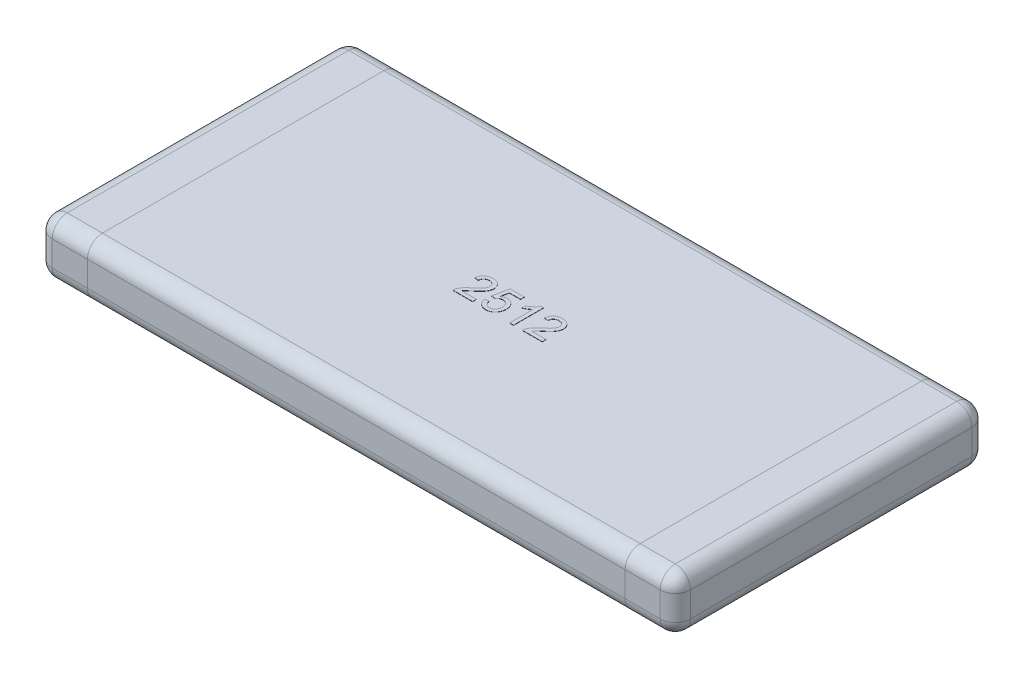
from build123d import *

# Parameters (mm, degrees)
SKETCH1_W      = 6.35
SKETCH1_H      = 3.1
EXTRUDE1_DEPTH = 0.55
FILLET1_R      = 0.15
EXTRUDE2_DEPTH = 0.002


with BuildPart() as part:
    # Sketch1 → Extrude1 (new body)
    with BuildSketch(Plane(origin=(0, 0, 0), x_dir=(1, 0, 0), z_dir=(0, 1, 0))):
        Rectangle(SKETCH1_W, SKETCH1_H)
    extrude(amount=EXTRUDE1_DEPTH)

    # Fillet1
    fillet1_edges = [part.edges().sort_by_distance(p)[0] for p in [
        (3.175, 0.55, 0),
        (0, 0.55, -1.55),
        (-3.175, 0.55, 0),
        (0, 0, -1.55),
        (3.175, 0, 0),
        (0, 0, 1.55),
        (-3.175, 0, 0),
        (0, 0.55, 1.55),
        (-3.175, 0.275, -1.55),
        (3.175, 0.275, -1.55),
        (3.175, 0.275, 1.55),
        (-3.175, 0.275, 1.55),
    ]]
    fillet(fillet1_edges, radius=FILLET1_R)

    # Sketch3 → Extrude2 (add)
    with BuildSketch(Plane(origin=(0, 0.55, 0), x_dir=(1, 0, 0), z_dir=(0, 1, 0))):
        with BuildLine():
            Line((-0.242307692, -0.111538462), (-0.242307692, -0.15))
            Line((-0.242307692, -0.15), (-0.438461538, -0.15))
            add(Edge.make_bspline(
                [(-0.438461538, -0.15), (-0.438465554, -0.147714123), (-0.438473572, -0.14315003), (-0.437701254, -0.136400026), (-0.43649165, -0.129739566), (-0.43512395, -0.125468478), (-0.434435096, -0.123317308)],
                knots=[0, 0, 0, 0, 6.852e-06, 1.3681e-05, 2.0352e-05, 2.7121e-05, 2.7121e-05, 2.7121e-05, 2.7121e-05], degree=3))
            add(Edge.make_bspline(
                [(-0.434435096, -0.123317308), (-0.433162323, -0.119802551), (-0.430570749, -0.112645929), (-0.425320191, -0.102319922), (-0.419144294, -0.092056365), (-0.413131189, -0.08370038), (-0.407624483, -0.077024532), (-0.403006393, -0.071801454), (-0.397888702, -0.066455018), (-0.392275509, -0.060986201), (-0.386220838, -0.055359583), (-0.379716427, -0.049556401), (-0.37268547, -0.043684801), (-0.367777126, -0.039792861), (-0.365264423, -0.037800481)],
                knots=[0, 0, 0, 0, 1.1205e-05, 2.2816e-05, 3.4678e-05, 4.712e-05, 5.3653e-05, 6.0635e-05, 6.8031e-05, 7.5851e-05, 8.4142e-05, 9.2826e-05, 0.000101998, 0.000111618, 0.000111618, 0.000111618, 0.000111618], degree=3))
            add(Edge.make_bspline(
                [(-0.365264423, -0.037800481), (-0.361404291, -0.034551471), (-0.353971363, -0.028295295), (-0.343474903, -0.019011711), (-0.333888095, -0.010391377), (-0.325363599, -0.002283205), (-0.317831693, 0.005234162), (-0.311274691, 0.012143692), (-0.305636176, 0.018423822), (-0.300984983, 0.024301865), (-0.297060629, 0.029852373), (-0.293735085, 0.035266551), (-0.290963685, 0.040638972), (-0.28865548, 0.045952637), (-0.286829886, 0.05123027), (-0.285585484, 0.056487246), (-0.284741574, 0.061671403), (-0.28465714, 0.065120999), (-0.284615385, 0.066826923)],
                knots=[0, 0, 0, 0, 1.5136e-05, 2.9145e-05, 4.2036e-05, 5.3811e-05, 6.4435e-05, 7.3957e-05, 8.2386e-05, 8.9745e-05, 9.643e-05, 0.000102769, 0.00010879, 0.00011455, 0.000120137, 0.000125516, 0.000130743, 0.000135857, 0.000135857, 0.000135857, 0.000135857], degree=3))
            add(Edge.make_bspline(
                [(-0.284615385, 0.066826923), (-0.284657145, 0.068512943), (-0.284739075, 0.071820821), (-0.285516432, 0.076661881), (-0.286598573, 0.081323937), (-0.288348068, 0.085723063), (-0.290430492, 0.089989532), (-0.293101705, 0.093988532), (-0.296191748, 0.097819726), (-0.299729586, 0.101382104), (-0.303593734, 0.104724183), (-0.307911369, 0.107502263), (-0.312398909, 0.110003363), (-0.317211172, 0.11201439), (-0.322340336, 0.113491124), (-0.327749065, 0.114562852), (-0.333436501, 0.115242385), (-0.337317775, 0.115336486), (-0.339302885, 0.115384615)],
                knots=[0, 0, 0, 0, 5.054e-06, 9.915e-06, 1.4681e-05, 1.938e-05, 2.4083e-05, 2.89e-05, 3.3772e-05, 3.8829e-05, 4.3946e-05, 4.9063e-05, 5.4199e-05, 5.9345e-05, 6.4669e-05, 7.0185e-05, 7.5872e-05, 8.1827e-05, 8.1827e-05, 8.1827e-05, 8.1827e-05], degree=3))
            add(Edge.make_bspline(
                [(-0.339302885, 0.115384615), (-0.341388187, 0.115336725), (-0.345469276, 0.115242999), (-0.351434735, 0.114560756), (-0.357097905, 0.113518381), (-0.362445268, 0.111924678), (-0.367470315, 0.109917004), (-0.372152582, 0.107389877), (-0.376567049, 0.104537208), (-0.38057469, 0.101159863), (-0.384198747, 0.097415076), (-0.387416066, 0.093338135), (-0.390052175, 0.088850365), (-0.392229183, 0.084050442), (-0.393979679, 0.078923275), (-0.39525048, 0.07342967), (-0.395943329, 0.067585487), (-0.396082655, 0.063583392), (-0.396153846, 0.061538462)],
                knots=[0, 0, 0, 0, 6.255e-06, 1.2241e-05, 1.7992e-05, 2.3507e-05, 2.8953e-05, 3.4195e-05, 3.9446e-05, 4.4693e-05, 4.9878e-05, 5.506e-05, 6.0233e-05, 6.5451e-05, 7.0848e-05, 7.6461e-05, 8.2334e-05, 8.8471e-05, 8.8471e-05, 8.8471e-05, 8.8471e-05], degree=3))
            Line((-0.396153846, 0.061538462), (-0.434615385, 0.065384615))
            add(Edge.make_bspline(
                [(-0.434615385, 0.065384615), (-0.434221868, 0.068736632), (-0.433456317, 0.075257693), (-0.431549431, 0.084702351), (-0.428872337, 0.09348859), (-0.425668968, 0.101738909), (-0.421653243, 0.109312863), (-0.417113811, 0.11636711), (-0.411759761, 0.122677919), (-0.405844956, 0.128444216), (-0.399304593, 0.133525841), (-0.392200109, 0.137965346), (-0.384534753, 0.141678718), (-0.376351219, 0.144753235), (-0.367630719, 0.147085948), (-0.358385591, 0.148758724), (-0.348600965, 0.149789842), (-0.341889572, 0.149928948), (-0.338461538, 0.15)],
                knots=[0, 0, 0, 0, 1.0123e-05, 1.9693e-05, 2.8857e-05, 3.7651e-05, 4.6199e-05, 5.4533e-05, 6.2766e-05, 7.0968e-05, 7.9275e-05, 8.7563e-05, 9.6056e-05, 0.000104785, 0.00011375, 0.000123098, 0.000132946, 0.000143229, 0.000143229, 0.000143229, 0.000143229], degree=3))
            add(Edge.make_bspline(
                [(-0.338461538, 0.15), (-0.334992474, 0.149940596), (-0.328234715, 0.149824877), (-0.318387574, 0.14864084), (-0.309096525, 0.146796713), (-0.300327506, 0.144226564), (-0.292132326, 0.140856333), (-0.284504682, 0.136738671), (-0.277409403, 0.131913745), (-0.270965038, 0.126323636), (-0.265153985, 0.120221095), (-0.260061454, 0.113708369), (-0.255803853, 0.106813279), (-0.25217877, 0.09962981), (-0.249489912, 0.092006182), (-0.247599058, 0.084046037), (-0.246314167, 0.075742575), (-0.246207997, 0.070077103), (-0.246153846, 0.0671875)],
                knots=[0, 0, 0, 0, 1.0403e-05, 2.0265e-05, 2.9705e-05, 3.8794e-05, 4.7633e-05, 5.6238e-05, 6.4755e-05, 7.3321e-05, 8.178e-05, 9.0002e-05, 9.8073e-05, 0.000106055, 0.000114096, 0.000122258, 0.000130579, 0.00013924, 0.00013924, 0.00013924, 0.00013924], degree=3))
            add(Edge.make_bspline(
                [(-0.246153846, 0.0671875), (-0.246236534, 0.06421876), (-0.246402091, 0.058274728), (-0.247694287, 0.049390154), (-0.24990525, 0.040601997), (-0.252836396, 0.0318033), (-0.256840951, 0.022959142), (-0.261900028, 0.013947517), (-0.268176364, 0.004735138), (-0.27421244, -0.003096409), (-0.279831048, -0.009661219), (-0.284811412, -0.015064442), (-0.290573405, -0.020805005), (-0.296900874, -0.027081717), (-0.304051882, -0.033671804), (-0.311820964, -0.040772611), (-0.32037819, -0.048197271), (-0.326318573, -0.053269443), (-0.329387019, -0.055889423)],
                knots=[0, 0, 0, 0, 8.904e-06, 1.7828e-05, 2.6865e-05, 3.6063e-05, 4.5612e-05, 5.5944e-05, 6.7028e-05, 7.9024e-05, 8.5588e-05, 9.2946e-05, 0.000101063, 0.000109987, 0.000119681, 0.000130232, 0.000141562, 0.000153666, 0.000153666, 0.000153666, 0.000153666], degree=3))
            add(Edge.make_bspline(
                [(-0.329387019, -0.055889423), (-0.33201468, -0.058028619), (-0.337025225, -0.062107737), (-0.344153696, -0.068021343), (-0.350538638, -0.07344396), (-0.356329361, -0.078198712), (-0.361314972, -0.08251558), (-0.365671081, -0.086205504), (-0.369239429, -0.089454013), (-0.374673391, -0.094388563), (-0.381555968, -0.101422266), (-0.386627345, -0.108256719), (-0.3890625, -0.111538462)],
                knots=[0, 0, 0, 0, 1.0165e-05, 1.9383e-05, 2.7786e-05, 3.5295e-05, 4.1859e-05, 4.7569e-05, 5.242e-05, 5.6334e-05, 6.9594e-05, 8.1844e-05, 8.1844e-05, 8.1844e-05, 8.1844e-05], degree=3))
            Line((-0.3890625, -0.111538462), (-0.242307692, -0.111538462))
        make_face()
        with BuildLine():
            Line((-0.2, -0.069230769), (-0.161538462, -0.065384615))
            add(Edge.make_bspline(
                [(-0.161538462, -0.065384615), (-0.161157632, -0.067551712), (-0.160416859, -0.071767052), (-0.159005235, -0.077868882), (-0.157171936, -0.083537652), (-0.155112024, -0.088822457), (-0.15266347, -0.093667418), (-0.150010442, -0.098149034), (-0.146881737, -0.102108221), (-0.143592325, -0.105752048), (-0.139981943, -0.108962904), (-0.136015755, -0.111669767), (-0.131804419, -0.114031341), (-0.127296644, -0.115964892), (-0.12248552, -0.11738015), (-0.11743228, -0.118499376), (-0.112071855, -0.119063349), (-0.108414474, -0.119174249), (-0.106550481, -0.119230769)],
                knots=[0, 0, 0, 0, 6.601e-06, 1.2839e-05, 1.8769e-05, 2.4461e-05, 2.9836e-05, 3.5041e-05, 4.0053e-05, 4.4945e-05, 4.9756e-05, 5.4507e-05, 5.9322e-05, 6.4223e-05, 6.9184e-05, 7.4347e-05, 7.9729e-05, 8.5323e-05, 8.5323e-05, 8.5323e-05, 8.5323e-05], degree=3))
            add(Edge.make_bspline(
                [(-0.106550481, -0.119230769), (-0.104263779, -0.119175516), (-0.099792033, -0.119067466), (-0.09328649, -0.118153619), (-0.087141479, -0.116646792), (-0.0813864, -0.1145381), (-0.075953789, -0.111915691), (-0.071023867, -0.10852015), (-0.066327829, -0.104703226), (-0.062167866, -0.10015272), (-0.058381131, -0.095198734), (-0.055112894, -0.089791248), (-0.0523615, -0.08400616), (-0.050045127, -0.077844578), (-0.048334654, -0.071271305), (-0.047076464, -0.064321309), (-0.046268755, -0.056990161), (-0.046192692, -0.051965295), (-0.046153846, -0.049399038)],
                knots=[0, 0, 0, 0, 6.858e-06, 1.341e-05, 1.9663e-05, 2.5804e-05, 3.177e-05, 3.7704e-05, 4.3721e-05, 4.9886e-05, 5.6149e-05, 6.2405e-05, 6.8802e-05, 7.5343e-05, 8.2122e-05, 8.9147e-05, 9.652e-05, 0.000104216, 0.000104216, 0.000104216, 0.000104216], degree=3))
            add(Edge.make_bspline(
                [(-0.046153846, -0.049399038), (-0.046197998, -0.04695343), (-0.046283972, -0.042191262), (-0.047008016, -0.035256754), (-0.048229562, -0.028736217), (-0.049810129, -0.022557785), (-0.05198874, -0.016818003), (-0.054572696, -0.01143365), (-0.057738151, -0.006518997), (-0.061259928, -0.001921019), (-0.065282243, 0.002200882), (-0.069859435, 0.005681305), (-0.074811944, 0.008727379), (-0.080239519, 0.011197555), (-0.086145356, 0.013032802), (-0.092470767, 0.01444486), (-0.099281388, 0.015187545), (-0.103964807, 0.015317745), (-0.106370192, 0.015384615)],
                knots=[0, 0, 0, 0, 7.336e-06, 1.4284e-05, 2.0885e-05, 2.7226e-05, 3.3387e-05, 3.9274e-05, 4.5109e-05, 5.0891e-05, 5.6628e-05, 6.2325e-05, 6.8097e-05, 7.4041e-05, 8.016e-05, 8.662e-05, 9.3456e-05, 0.000100674, 0.000100674, 0.000100674, 0.000100674], degree=3))
            add(Edge.make_bspline(
                [(-0.106370192, 0.015384615), (-0.109361172, 0.015297123), (-0.115097193, 0.015129334), (-0.123339267, 0.013717778), (-0.130842324, 0.011437589), (-0.137521417, 0.008039245), (-0.143488856, 0.003979366), (-0.148868613, -0.000614572), (-0.153705047, -0.005739463), (-0.156358029, -0.009597911), (-0.157692308, -0.011538462)],
                knots=[0, 0, 0, 0, 8.967e-06, 1.7197e-05, 2.5009e-05, 3.24e-05, 3.9584e-05, 4.6617e-05, 5.3591e-05, 6.0647e-05, 6.0647e-05, 6.0647e-05, 6.0647e-05], degree=3))
            Line((-0.157692308, -0.011538462), (-0.196153846, -0.007692308))
            Line((-0.196153846, -0.007692308), (-0.165384615, 0.146153846))
            Line((-0.165384615, 0.146153846), (-0.023076923, 0.146153846))
            Line((-0.023076923, 0.146153846), (-0.023076923, 0.107692308))
            Line((-0.023076923, 0.107692308), (-0.133954327, 0.107692308))
            Line((-0.133954327, 0.107692308), (-0.14921875, 0.029987981))
            add(Edge.make_bspline(
                [(-0.14921875, 0.029987981), (-0.147096545, 0.031580513), (-0.142928871, 0.034707994), (-0.136428046, 0.038803019), (-0.129834266, 0.042254851), (-0.123185915, 0.045081612), (-0.116430183, 0.047283653), (-0.109607836, 0.04881353), (-0.102695646, 0.049847511), (-0.098060615, 0.049949025), (-0.095733173, 0.05)],
                knots=[0, 0, 0, 0, 7.957e-06, 1.5627e-05, 2.3019e-05, 3.0263e-05, 3.7276e-05, 4.4303e-05, 5.1221e-05, 5.8199e-05, 5.8199e-05, 5.8199e-05, 5.8199e-05], degree=3))
            add(Edge.make_bspline(
                [(-0.095733173, 0.05), (-0.092704165, 0.049920638), (-0.086739314, 0.049764354), (-0.077949899, 0.048480285), (-0.06954574, 0.046300494), (-0.061460916, 0.043364633), (-0.053802033, 0.039472647), (-0.046491513, 0.034760279), (-0.039558872, 0.029188686), (-0.033043301, 0.022862992), (-0.027133419, 0.015840807), (-0.021843881, 0.008351149), (-0.017523676, 0.000244097), (-0.013890087, -0.008268674), (-0.011149556, -0.017326903), (-0.009069398, -0.026802035), (-0.007957206, -0.036812532), (-0.007781989, -0.043627351), (-0.007692308, -0.047115385)],
                knots=[0, 0, 0, 0, 9.084e-06, 1.7889e-05, 2.6576e-05, 3.5094e-05, 4.3641e-05, 5.2292e-05, 6.1143e-05, 7.028e-05, 7.9491e-05, 8.8643e-05, 9.7732e-05, 0.000106996, 0.000116367, 0.00012608, 0.000136061, 0.000146526, 0.000146526, 0.000146526, 0.000146526], degree=3))
            add(Edge.make_bspline(
                [(-0.007692308, -0.047115385), (-0.007760408, -0.050443542), (-0.007894924, -0.057017604), (-0.008997316, -0.066705698), (-0.010813244, -0.07604094), (-0.013244271, -0.085050973), (-0.016528915, -0.093684628), (-0.02051288, -0.101969792), (-0.025108607, -0.109992917), (-0.028794142, -0.114938711), (-0.030649038, -0.117427885)],
                knots=[0, 0, 0, 0, 9.982e-06, 1.9718e-05, 2.9206e-05, 3.8493e-05, 4.7679e-05, 5.6872e-05, 6.6056e-05, 7.5361e-05, 7.5361e-05, 7.5361e-05, 7.5361e-05], degree=3))
            add(Edge.make_bspline(
                [(-0.030649038, -0.117427885), (-0.033005632, -0.120333533), (-0.037641305, -0.126049256), (-0.045667922, -0.133467922), (-0.054296649, -0.139772767), (-0.063578837, -0.144894997), (-0.073452171, -0.149011142), (-0.084037943, -0.151750282), (-0.095208241, -0.153589724), (-0.102876868, -0.153759501), (-0.106790865, -0.153846154)],
                knots=[0, 0, 0, 0, 1.1212e-05, 2.2054e-05, 3.2681e-05, 4.3199e-05, 5.379e-05, 6.4679e-05, 7.5933e-05, 8.7664e-05, 8.7664e-05, 8.7664e-05, 8.7664e-05], degree=3))
            add(Edge.make_bspline(
                [(-0.106790865, -0.153846154), (-0.110019293, -0.153780666), (-0.116334744, -0.153652558), (-0.125581689, -0.152538848), (-0.134376627, -0.150762874), (-0.142722313, -0.148215578), (-0.150643892, -0.144996831), (-0.158049284, -0.140907918), (-0.165067002, -0.136230457), (-0.17154268, -0.130820335), (-0.177442866, -0.124785969), (-0.182729553, -0.118255214), (-0.187331197, -0.111223812), (-0.191245577, -0.103733837), (-0.194508032, -0.095792473), (-0.197003939, -0.087345515), (-0.198980905, -0.078475843), (-0.19965674, -0.072344773), (-0.2, -0.069230769)],
                knots=[0, 0, 0, 0, 9.682e-06, 1.894e-05, 2.7898e-05, 3.6567e-05, 4.5082e-05, 5.3499e-05, 6.19e-05, 7.0348e-05, 7.8763e-05, 8.7181e-05, 9.5515e-05, 0.000103929, 0.0001125, 0.000121226, 0.000130326, 0.000139718, 0.000139718, 0.000139718, 0.000139718], degree=3))
        make_face()
        with BuildLine():
            Line((0.165384615, -0.15), (0.126923077, -0.15))
            Line((0.126923077, -0.15), (0.126923077, 0.083774038))
            add(Edge.make_bspline(
                [(0.126923077, 0.083774038), (0.124708458, 0.081638311), (0.120105616, 0.077199436), (0.112324997, 0.070917319), (0.103640832, 0.064550127), (0.09416589, 0.05842736), (0.08450779, 0.052663436), (0.075174479, 0.047479672), (0.066321782, 0.04309295), (0.060490463, 0.040694273), (0.057692308, 0.039543269)],
                knots=[0, 0, 0, 0, 9.226e-06, 1.9175e-05, 2.9969e-05, 4.1521e-05, 5.3002e-05, 6.3707e-05, 7.3544e-05, 8.2619e-05, 8.2619e-05, 8.2619e-05, 8.2619e-05], degree=3))
            Line((0.057692308, 0.039543269), (0.057692308, 0.075))
            add(Edge.make_bspline(
                [(0.057692308, 0.075), (0.062498428, 0.077475162), (0.071971006, 0.082353558), (0.085353711, 0.09077922), (0.097847906, 0.099912985), (0.109246762, 0.10975283), (0.11946511, 0.119810917), (0.128076261, 0.129959923), (0.135281523, 0.139827828), (0.13889654, 0.146709597), (0.140625, 0.15)],
                knots=[0, 0, 0, 0, 1.6212e-05, 3.1953e-05, 4.7386e-05, 6.26e-05, 7.7091e-05, 9.0349e-05, 0.000102505, 0.000113642, 0.000113642, 0.000113642, 0.000113642], degree=3))
            Line((0.140625, 0.15), (0.165384615, 0.15))
            Line((0.165384615, 0.15), (0.165384615, -0.15))
        make_face()
        with BuildLine():
            Line((0.45, -0.111538462), (0.45, -0.15))
            Line((0.45, -0.15), (0.253846154, -0.15))
            add(Edge.make_bspline(
                [(0.253846154, -0.15), (0.253842138, -0.147714123), (0.25383412, -0.14315003), (0.254606438, -0.136400026), (0.255816043, -0.129739566), (0.257183742, -0.125468478), (0.257872596, -0.123317308)],
                knots=[0, 0, 0, 0, 6.852e-06, 1.3681e-05, 2.0352e-05, 2.7121e-05, 2.7121e-05, 2.7121e-05, 2.7121e-05], degree=3))
            add(Edge.make_bspline(
                [(0.257872596, -0.123317308), (0.259145369, -0.119802551), (0.261736944, -0.112645929), (0.266987502, -0.102319922), (0.273163399, -0.092056365), (0.279176504, -0.08370038), (0.284683209, -0.077024532), (0.2893013, -0.071801454), (0.294418991, -0.066455018), (0.300032183, -0.060986201), (0.306086854, -0.055359583), (0.312591265, -0.049556401), (0.319622223, -0.043684801), (0.324530567, -0.039792861), (0.327043269, -0.037800481)],
                knots=[0, 0, 0, 0, 1.1205e-05, 2.2816e-05, 3.4678e-05, 4.712e-05, 5.3653e-05, 6.0635e-05, 6.8031e-05, 7.5851e-05, 8.4142e-05, 9.2826e-05, 0.000101998, 0.000111618, 0.000111618, 0.000111618, 0.000111618], degree=3))
            add(Edge.make_bspline(
                [(0.327043269, -0.037800481), (0.330903401, -0.034551471), (0.33833633, -0.028295295), (0.348832789, -0.019011711), (0.358419597, -0.010391377), (0.366944093, -0.002283205), (0.374476, 0.005234162), (0.381033001, 0.012143692), (0.386671516, 0.018423822), (0.391322709, 0.024301865), (0.395247064, 0.029852373), (0.398572608, 0.035266551), (0.401344007, 0.040638972), (0.403652212, 0.045952637), (0.405477806, 0.05123027), (0.406722208, 0.056487246), (0.407566119, 0.061671403), (0.407650553, 0.065120999), (0.407692308, 0.066826923)],
                knots=[0, 0, 0, 0, 1.5136e-05, 2.9145e-05, 4.2036e-05, 5.3811e-05, 6.4435e-05, 7.3957e-05, 8.2386e-05, 8.9745e-05, 9.643e-05, 0.000102769, 0.00010879, 0.00011455, 0.000120137, 0.000125516, 0.000130743, 0.000135857, 0.000135857, 0.000135857, 0.000135857], degree=3))
            add(Edge.make_bspline(
                [(0.407692308, 0.066826923), (0.407650548, 0.068512943), (0.407568617, 0.071820821), (0.406791261, 0.076661881), (0.405709119, 0.081323937), (0.403959625, 0.085723063), (0.4018772, 0.089989532), (0.399205988, 0.093988532), (0.396115944, 0.097819726), (0.392578106, 0.101382104), (0.388713958, 0.104724183), (0.384396323, 0.107502263), (0.379908783, 0.110003363), (0.375096521, 0.11201439), (0.369967356, 0.113491124), (0.364558627, 0.114562852), (0.358871192, 0.115242385), (0.354989917, 0.115336486), (0.353004808, 0.115384615)],
                knots=[0, 0, 0, 0, 5.054e-06, 9.915e-06, 1.4681e-05, 1.938e-05, 2.4083e-05, 2.89e-05, 3.3772e-05, 3.8829e-05, 4.3946e-05, 4.9063e-05, 5.4199e-05, 5.9345e-05, 6.4669e-05, 7.0185e-05, 7.5872e-05, 8.1827e-05, 8.1827e-05, 8.1827e-05, 8.1827e-05], degree=3))
            add(Edge.make_bspline(
                [(0.353004808, 0.115384615), (0.350919506, 0.115336725), (0.346838417, 0.115242999), (0.340872957, 0.114560756), (0.335209788, 0.113518381), (0.329862425, 0.111924678), (0.324837377, 0.109917004), (0.320155111, 0.107389877), (0.315740643, 0.104537208), (0.311733002, 0.101159863), (0.308108946, 0.097415076), (0.304891627, 0.093338135), (0.302255517, 0.088850365), (0.30007851, 0.084050442), (0.298328013, 0.078923275), (0.297057212, 0.07342967), (0.296364363, 0.067585487), (0.296225037, 0.063583392), (0.296153846, 0.061538462)],
                knots=[0, 0, 0, 0, 6.255e-06, 1.2241e-05, 1.7992e-05, 2.3507e-05, 2.8953e-05, 3.4195e-05, 3.9446e-05, 4.4693e-05, 4.9878e-05, 5.506e-05, 6.0233e-05, 6.5451e-05, 7.0848e-05, 7.6461e-05, 8.2334e-05, 8.8471e-05, 8.8471e-05, 8.8471e-05, 8.8471e-05], degree=3))
            Line((0.296153846, 0.061538462), (0.257692308, 0.065384615))
            add(Edge.make_bspline(
                [(0.257692308, 0.065384615), (0.258085824, 0.068736632), (0.258851376, 0.075257693), (0.260758261, 0.084702351), (0.263435355, 0.09348859), (0.266638724, 0.101738909), (0.27065445, 0.109312863), (0.275193881, 0.11636711), (0.280547932, 0.122677919), (0.286462737, 0.128444216), (0.293003099, 0.133525841), (0.300107584, 0.137965346), (0.30777294, 0.141678718), (0.315956474, 0.144753235), (0.324676973, 0.147085948), (0.333922102, 0.148758724), (0.343706727, 0.149789842), (0.350418121, 0.149928948), (0.353846154, 0.15)],
                knots=[0, 0, 0, 0, 1.0123e-05, 1.9693e-05, 2.8857e-05, 3.7651e-05, 4.6199e-05, 5.4533e-05, 6.2766e-05, 7.0968e-05, 7.9275e-05, 8.7563e-05, 9.6056e-05, 0.000104785, 0.00011375, 0.000123098, 0.000132946, 0.000143229, 0.000143229, 0.000143229, 0.000143229], degree=3))
            add(Edge.make_bspline(
                [(0.353846154, 0.15), (0.357315219, 0.149940596), (0.364072977, 0.149824877), (0.373920118, 0.14864084), (0.383211167, 0.146796713), (0.391980186, 0.144226564), (0.400175366, 0.140856333), (0.40780301, 0.136738671), (0.414898289, 0.131913745), (0.421342655, 0.126323636), (0.427153708, 0.120221095), (0.432246239, 0.113708369), (0.43650384, 0.106813279), (0.440128923, 0.09962981), (0.44281778, 0.092006182), (0.444708635, 0.084046037), (0.445993525, 0.075742575), (0.446099695, 0.070077103), (0.446153846, 0.0671875)],
                knots=[0, 0, 0, 0, 1.0403e-05, 2.0265e-05, 2.9705e-05, 3.8794e-05, 4.7633e-05, 5.6238e-05, 6.4755e-05, 7.3321e-05, 8.178e-05, 9.0002e-05, 9.8073e-05, 0.000106055, 0.000114096, 0.000122258, 0.000130579, 0.00013924, 0.00013924, 0.00013924, 0.00013924], degree=3))
            add(Edge.make_bspline(
                [(0.446153846, 0.0671875), (0.446071159, 0.06421876), (0.445905602, 0.058274728), (0.444613405, 0.049390154), (0.442402443, 0.040601997), (0.439471297, 0.0318033), (0.435466741, 0.022959142), (0.430407665, 0.013947517), (0.424131328, 0.004735138), (0.418095252, -0.003096409), (0.412476645, -0.009661219), (0.40749628, -0.015064442), (0.401734287, -0.020805005), (0.395406818, -0.027081717), (0.38825581, -0.033671804), (0.380486728, -0.040772611), (0.371929502, -0.048197271), (0.36598912, -0.053269443), (0.362920673, -0.055889423)],
                knots=[0, 0, 0, 0, 8.904e-06, 1.7828e-05, 2.6865e-05, 3.6063e-05, 4.5612e-05, 5.5944e-05, 6.7028e-05, 7.9024e-05, 8.5588e-05, 9.2946e-05, 0.000101063, 0.000109987, 0.000119681, 0.000130232, 0.000141562, 0.000153666, 0.000153666, 0.000153666, 0.000153666], degree=3))
            add(Edge.make_bspline(
                [(0.362920673, -0.055889423), (0.360293012, -0.058028619), (0.355282467, -0.062107737), (0.348153996, -0.068021343), (0.341769055, -0.07344396), (0.335978331, -0.078198712), (0.33099272, -0.08251558), (0.326636611, -0.086205504), (0.323068263, -0.089454013), (0.317634301, -0.094388563), (0.310751724, -0.101422266), (0.305680348, -0.108256719), (0.303245192, -0.111538462)],
                knots=[0, 0, 0, 0, 1.0165e-05, 1.9383e-05, 2.7786e-05, 3.5295e-05, 4.1859e-05, 4.7569e-05, 5.242e-05, 5.6334e-05, 6.9594e-05, 8.1844e-05, 8.1844e-05, 8.1844e-05, 8.1844e-05], degree=3))
            Line((0.303245192, -0.111538462), (0.45, -0.111538462))
        make_face()
    extrude(amount=EXTRUDE2_DEPTH)


solid = part.part
